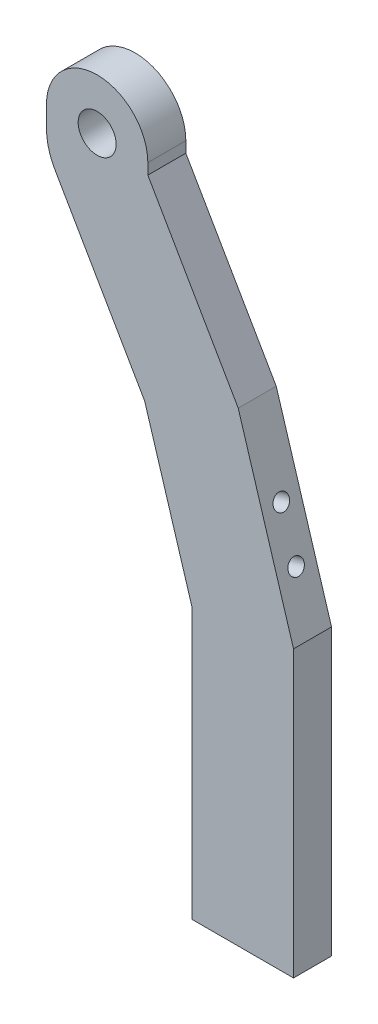
from build123d import *

# Parameters (mm, degrees)
SKETCH_1_R                       = 3
EXTRUDE_1_DEPTH                  = 6
SKETCH_2_W                       = 16
SKETCH_2_H                       = 26
SKETCH_2_R                       = 1.6
EXTRUDE_2_DEPTH                  = 6
FILLET_2_R                       = 10
FILLET_3_R                       = 2
SKETCH_3_W                       = 39.771534619
SKETCH_3_H                       = 15.568928143
CUT_EXTRUDE_1_DEPTH              = 16
HOLE_WIZARD_M3_1_D               = 2.5
HOLE_WIZARD_M3_1_DEPTH           = 7.5
HOLE_WIZARD_M3_1_TIP             = 0.751075774
CUT_EXTRUDE_2_DEPTH              = 7
EXTRUDE_3_DEPTH                  = 6
HOLE_WIZARD_M3_3_D               = 2.5
HOLE_WIZARD_M3_3_DEPTH           = 7.5
HOLE_WIZARD_M3_3_TIP             = 0.751075774
HOLE_WIZARD_M3_3_ON_FACE_2_D     = 2.5
HOLE_WIZARD_M3_3_ON_FACE_2_DEPTH = 7.5
HOLE_WIZARD_M3_3_ON_FACE_2_TIP   = 0.751075774


with BuildPart() as part:
    # 草图1 → 凸台-拉伸1 (new body)
    with BuildSketch(Plane.XY):
        with BuildLine():
            Line((19.167299473, 7.939450352), (-3.832700527, 47.776618926))
            Line((-3.832700527, 47.776618926), (-3.832700527, 49.489431847))
            ThreePointArc((-3.832700527, 49.489431847), (-11.832700527, 57.489431847), (-19.832700527, 49.489431847))
            Line((-19.832700527, 49.489431847), (-19.832700527, 43.489431847))
            Line((-19.832700527, 43.489431847), (3.167299473, 3.652263273))
            Line((3.167299473, 3.652263273), (3.167299473, -56.491330266))
            Line((3.167299473, -56.491330266), (19.167299473, -56.491330266))
            Line((19.167299473, -56.491330266), (19.167299473, 7.939450352))
        make_face()
        with Locations((-11.832700527, 49.489431847)):
            Circle(SKETCH_1_R, mode=Mode.SUBTRACT)
    extrude(amount=EXTRUDE_1_DEPTH)

    # 草图2 → 凸台-拉伸2 (add)
    with BuildSketch(Plane.XZ.offset(56.491330266)):
        with Locations((11.167299473, -7)):
            Rectangle(SKETCH_2_W, SKETCH_2_H)
        with Locations((7.167299473, -8)):
            Circle(SKETCH_2_R, mode=Mode.SUBTRACT)
        with Locations((15.167299473, -15)):
            Circle(SKETCH_2_R, mode=Mode.SUBTRACT)
    extrude(amount=-EXTRUDE_2_DEPTH)

    # 圆角2
    fillet_2_edges = [part.edges().sort_by_distance(p)[0] for p in [
        (-19.832700527, 43.489431847, 3),
    ]]
    fillet(fillet_2_edges, radius=FILLET_2_R)

    # 圆角3
    fillet_3_edges = [part.edges().sort_by_distance(p)[0] for p in [
        (3.167299473, -53.491330266, -20),
        (19.167299473, -53.491330266, -20),
    ]]
    fillet(fillet_3_edges, radius=FILLET_3_R)

    # 草图3 → 切除-拉伸1 (cut)
    with BuildSketch(Plane(origin=(19.167299473, 0, 0), x_dir=(0, 0, -1), z_dir=(1, 0, 0))):
        with Locations((8.066218502, -58.275794338)):
            Rectangle(SKETCH_3_W, SKETCH_3_H)
    extrude(amount=-CUT_EXTRUDE_1_DEPTH, mode=Mode.SUBTRACT)

    # M3 螺纹孔1
    with Locations(Plane(origin=(0, -50.491330266, 0), x_dir=(-1, 0, 0), z_dir=(0, -1, 0))):
        with Locations((-7.667299473, -3), (-14.667299473, -3)):
            Hole(HOLE_WIZARD_M3_1_D / 2, depth=HOLE_WIZARD_M3_1_DEPTH)
            with Locations((0, 0, -(HOLE_WIZARD_M3_1_DEPTH + HOLE_WIZARD_M3_1_TIP / 2))):  # 118° drill point
                Cone(0, HOLE_WIZARD_M3_1_D / 2, HOLE_WIZARD_M3_1_TIP, mode=Mode.SUBTRACT)

    # 草图9 → 切除-拉伸2 (cut, through all)
    with BuildSketch(Plane.XY.offset(6)):
        Polygon((10.439222522, 23.056923084), (29.925755937, 19.338586327), (19.167299473, -5.491330266), align=None)
    extrude(amount=-CUT_EXTRUDE_2_DEPTH, mode=Mode.SUBTRACT)

    # 草图12 → 凸台-拉伸3 (add)
    with BuildSketch(Plane.XY.offset(6)):
        Polygon((-4.328668805, 16.635661183), (3.167299473, -7.882546288), (3.167299473, 3.652263273), align=None)
    extrude(amount=-EXTRUDE_3_DEPTH)

    # M3 螺纹孔3
    with Locations(Plane(origin=(14.240054683, 10.624961257, 3), x_dir=(-0.292371705, 0.956304756, 0), z_dir=(0.956304756, 0.292371705, 0))):
        with Locations((0, 0)):
            Hole(HOLE_WIZARD_M3_3_D / 2, depth=HOLE_WIZARD_M3_3_DEPTH)
            with Locations((0, 0, -(HOLE_WIZARD_M3_3_DEPTH + HOLE_WIZARD_M3_3_TIP / 2))):  # 118° drill point
                Cone(0, HOLE_WIZARD_M3_3_D / 2, HOLE_WIZARD_M3_3_TIP, mode=Mode.SUBTRACT)

    # M3 螺纹孔3 on face 2
    with Locations(Plane(origin=(16.579028321, 2.974523209, 3), x_dir=(-0.292371907, 0.956304694, 0), z_dir=(0.956304694, 0.292371907, 0))):
        with Locations((0, 0)):
            Hole(HOLE_WIZARD_M3_3_ON_FACE_2_D / 2, depth=HOLE_WIZARD_M3_3_ON_FACE_2_DEPTH)
            with Locations((0, 0, -(HOLE_WIZARD_M3_3_ON_FACE_2_DEPTH + HOLE_WIZARD_M3_3_ON_FACE_2_TIP / 2))):  # 118° drill point
                Cone(0, HOLE_WIZARD_M3_3_ON_FACE_2_D / 2, HOLE_WIZARD_M3_3_ON_FACE_2_TIP, mode=Mode.SUBTRACT)


solid = part.part
